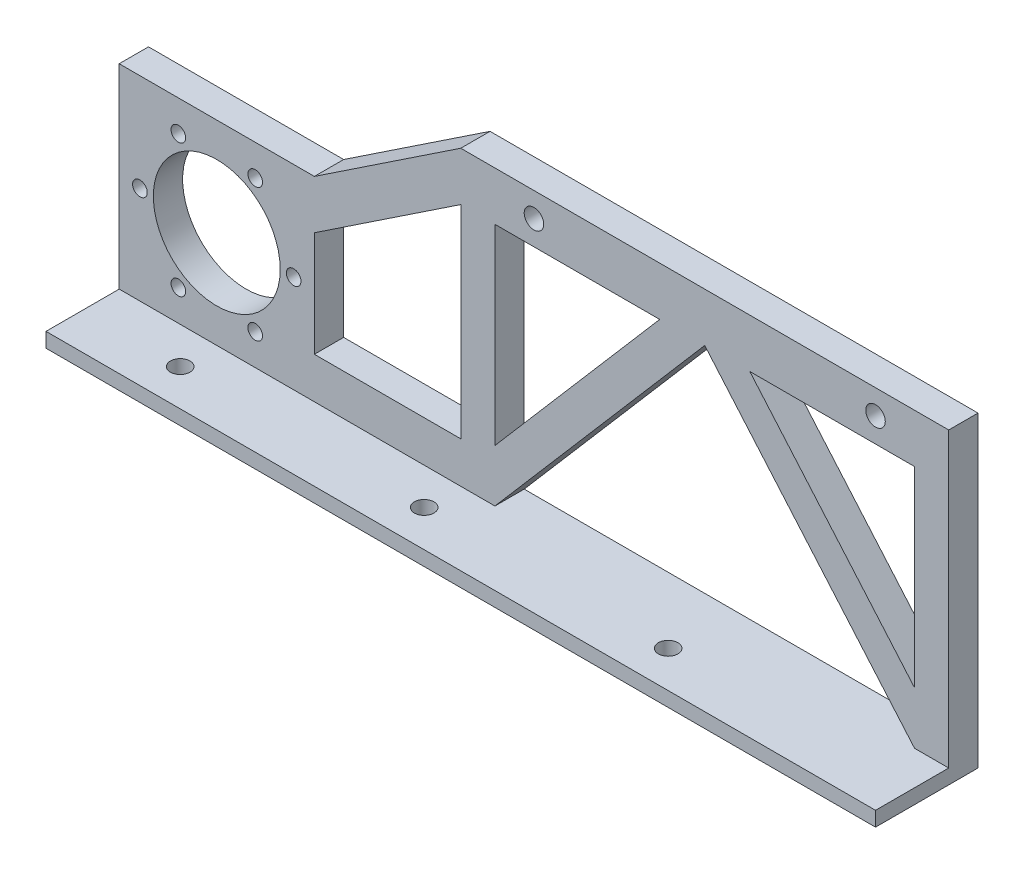
from build123d import *

# Parameters (mm, degrees)
SKETCH1_R                = 1.5
SKETCH1_R_2              = 13
SKETCH1_R_3              = 2
BOSS_EXTRUDE1_DEPTH      = 6
SKETCH2_W                = 170
SKETCH2_H                = 3
BOSS_EXTRUDE2_DEPTH      = 15
BOSS_EXTRUDE2_DEPTH_BACK = 6
SKETCH3_R                = 2
CUT_EXTRUDE1_DEPTH       = 15


with BuildPart() as part:
    # Sketch1 → Boss-Extrude1 (new body)
    with BuildSketch(Plane.XY):
        Polygon((50, 5), (-50, 5), (-80, -15), (-120, -15), (-120, -55), (-43, -55), (0, -5), (43, -55), (50, -55), align=None)
        Polygon((43, -5), (43, -44.264450265), (9.232572773, -5), align=None, mode=Mode.SUBTRACT)
        with Locations((-107.875, -48.63990011)):
            Circle(SKETCH1_R, mode=Mode.SUBTRACT)
        with Locations((-92.125, -48.63990011)):
            Circle(SKETCH1_R, mode=Mode.SUBTRACT)
        with Locations((-115.75, -35)):
            Circle(SKETCH1_R, mode=Mode.SUBTRACT)
        with Locations((-100, -35)):
            Circle(SKETCH1_R_2, mode=Mode.SUBTRACT)
        with Locations((-84.25, -35)):
            Circle(SKETCH1_R, mode=Mode.SUBTRACT)
        Polygon((-80, -46.571581383), (-80, -25), (-50, -5), (-50, -46.571581383), align=None, mode=Mode.SUBTRACT)
        Polygon((-43, -44.264450265), (-43, -5), (-9.232572773, -5), align=None, mode=Mode.SUBTRACT)
        with Locations((-107.875, -21.36009989)):
            Circle(SKETCH1_R, mode=Mode.SUBTRACT)
        with Locations((-92.125, -21.36009989)):
            Circle(SKETCH1_R, mode=Mode.SUBTRACT)
        with Locations((-35, 0)):
            Circle(SKETCH1_R_3, mode=Mode.SUBTRACT)
        with Locations((35, 0)):
            Circle(SKETCH1_R_3, mode=Mode.SUBTRACT)
    extrude(amount=BOSS_EXTRUDE1_DEPTH)

    # Sketch2 → Boss-Extrude2 (add, two sides)
    with BuildSketch(Plane.XY.offset(6)) as boss_extrude2_sk:
        with Locations((-35, -56.5)):
            Rectangle(SKETCH2_W, SKETCH2_H)
    extrude(amount=BOSS_EXTRUDE2_DEPTH)
    extrude(boss_extrude2_sk.sketch, amount=-BOSS_EXTRUDE2_DEPTH_BACK)

    # Sketch3 → Cut-Extrude1 (cut)
    with BuildSketch(Plane(origin=(0, -55, 0), x_dir=(1, 0, 0), z_dir=(0, 1, 0))):
        with Locations((0, -13.5)):
            Circle(SKETCH3_R)
        with Locations((-50, -13.5)):
            Circle(SKETCH3_R)
        with Locations((-100, -13.5)):
            Circle(SKETCH3_R)
    extrude(amount=-CUT_EXTRUDE1_DEPTH, mode=Mode.SUBTRACT)


solid = part.part
